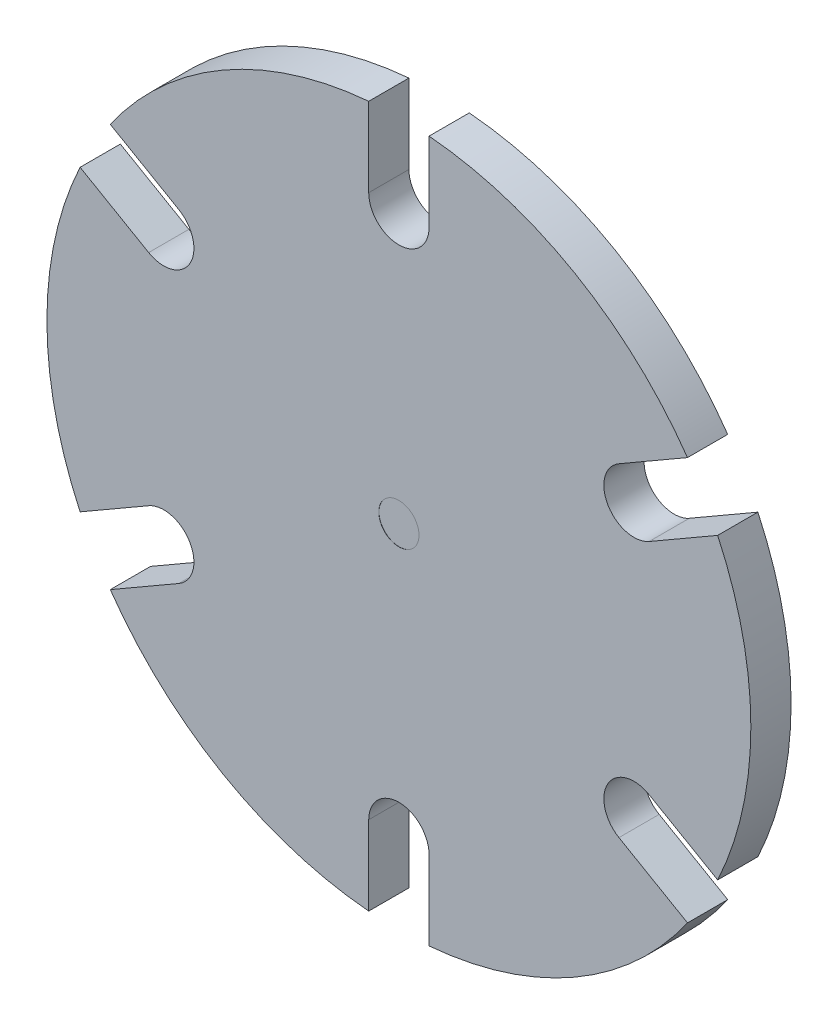
from build123d import *

# Parameters (mm, degrees)
SKETCH1_R           = 17.5
BOSS_EXTRUDE1_DEPTH = 2
SKETCH2_R           = 10
BOSS_EXTRUDE2_DEPTH = 1
CUT_EXTRUDE1_DEPTH  = 6
SKETCH5_R           = 1
CUT_EXTRUDE2_DEPTH  = 0.01
CIRPATTERN1_COUNT   = 6
FILLET1_R           = 0.3


with BuildPart() as part:
    # Sketch1 → Boss-Extrude1 (new body)
    with BuildSketch(Plane.XY):
        Circle(SKETCH1_R)
    extrude(amount=BOSS_EXTRUDE1_DEPTH)

    # Sketch2 → Boss-Extrude2 (add)
    with BuildSketch(Plane(origin=(0, 0, 0), x_dir=(-1, 0, 0), z_dir=(0, 0, -1))):
        Circle(SKETCH2_R)
    extrude(amount=BOSS_EXTRUDE2_DEPTH)

    # Sketch4 → Cut-Extrude1 (cut)
    with BuildSketch(Plane.XY.offset(2)):
        with BuildLine():
            Line((-1.5, 13.5), (-1.5, 17.5))
            Line((-1.5, 17.5), (1.5, 17.5))
            Line((1.5, 17.5), (1.5, 13.5))
            ThreePointArc((1.5, 13.5), (0, 12), (-1.5, 13.5))
        make_face()
    cut_extrude1 = extrude(amount=-CUT_EXTRUDE1_DEPTH, mode=Mode.SUBTRACT)

    # Sketch5 → Cut-Extrude2 (cut)
    with BuildSketch(Plane.XY.offset(2)):
        Circle(SKETCH5_R)
    extrude(amount=-CUT_EXTRUDE2_DEPTH, mode=Mode.SUBTRACT)

    # CirPattern1: Cut-Extrude1 ×6 about axis
    cirpattern1_axis = Axis((0, 0, 0), (0, 0, 1))
    for i in range(1, CIRPATTERN1_COUNT):
        add(cut_extrude1.rotate(cirpattern1_axis, i * 360 / CIRPATTERN1_COUNT), mode=Mode.SUBTRACT)

    # Fillet1
    fillet1_edges = [part.edges().sort_by_distance(p)[0] for p in [
        (10, 0, -1),
    ]]
    fillet(fillet1_edges, radius=FILLET1_R)


solid = part.part
